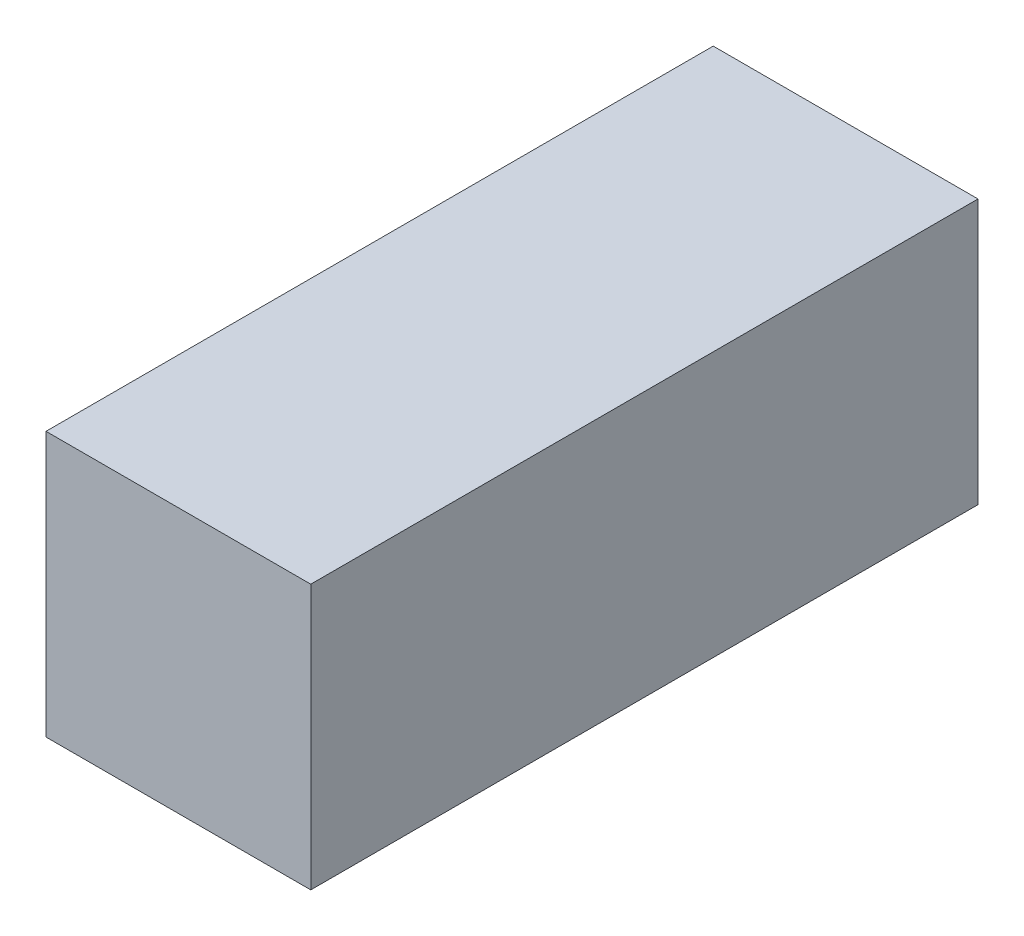
from build123d import *

# Parameters (mm, degrees)
SKETCH1_W           = 25
SKETCH1_H           = 25
BOSS_EXTRUDE1_DEPTH = 63


with BuildPart() as part:
    # Sketch1 → Boss-Extrude1 (new body)
    with BuildSketch(Plane.XY):
        with Locations((12.5, -12.5)):
            Rectangle(SKETCH1_W, SKETCH1_H)
    extrude(amount=BOSS_EXTRUDE1_DEPTH)


solid = part.part
